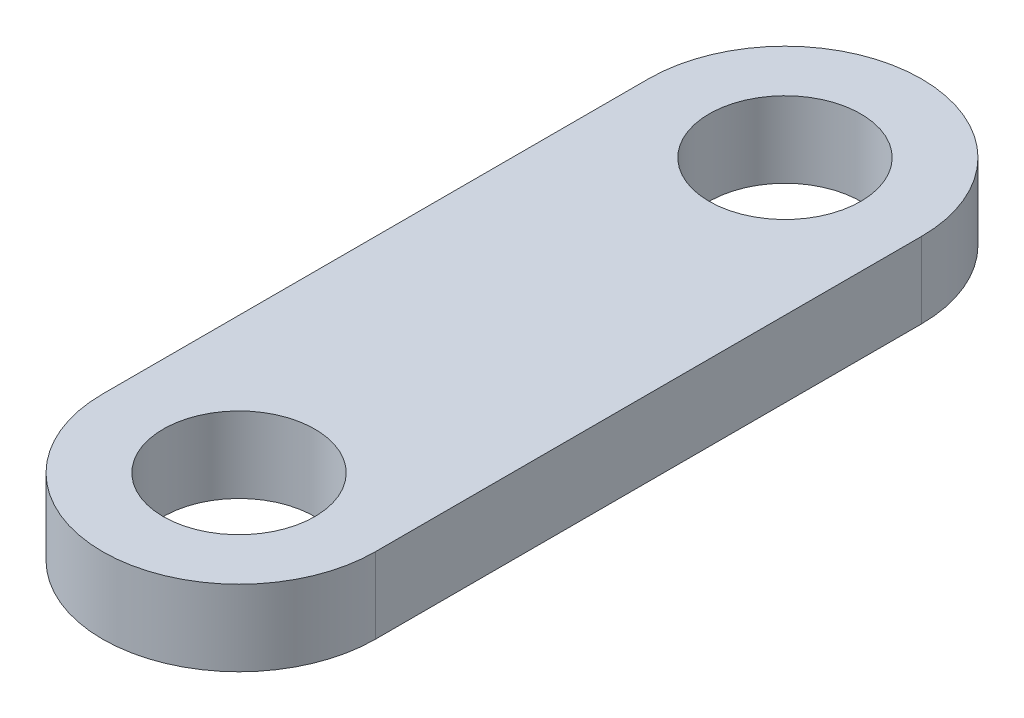
from build123d import *

# Parameters (mm, degrees)
SKETCH1_R           = 5
BOSS_EXTRUDE1_DEPTH = 5


with BuildPart() as part:
    # Sketch1 → Boss-Extrude1 (new body)
    with BuildSketch(Plane(origin=(0, 0, 0), x_dir=(1, 0, 0), z_dir=(0, 1, 0))):
        with BuildLine():
            Line((9, 0), (9, -36))
            ThreePointArc((9, -36), (0, -45), (-9, -36))
            Line((-9, -36), (-9, 0))
            ThreePointArc((-9, 0), (0, 9), (9, 0))
        make_face()
        Circle(SKETCH1_R, mode=Mode.SUBTRACT)
        with Locations((0, -36)):
            Circle(SKETCH1_R, mode=Mode.SUBTRACT)
    extrude(amount=BOSS_EXTRUDE1_DEPTH)


solid = part.part
